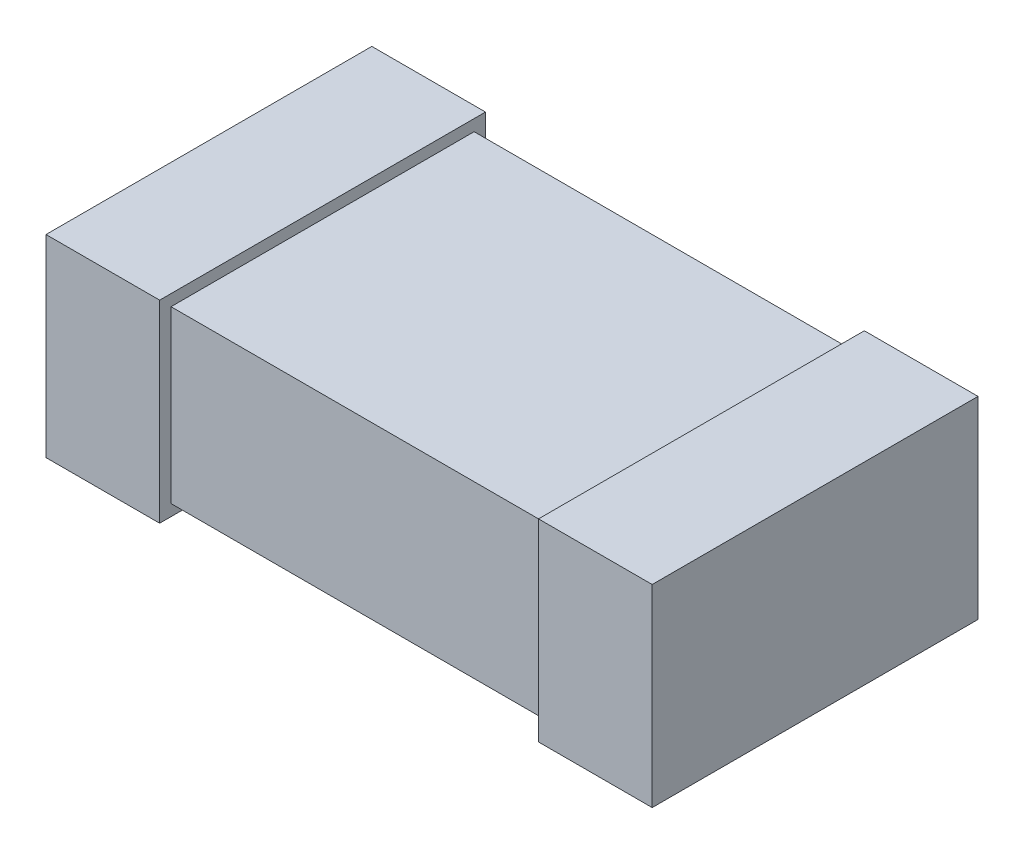
from build123d import *

# Parameters (mm, degrees)
SKETCH1_W           = 1
SKETCH1_H           = 0.8
BOSS_EXTRUDE1_DEPTH = 0.45
SKETCH2_W           = 0.3
SKETCH2_H           = 0.51
BOSS_EXTRUDE2_DEPTH = 0.86
SKETCH3_W           = 0.51
SKETCH3_H           = 0.86
BOSS_EXTRUDE3_DEPTH = 0.3


with BuildPart() as part:
    # Sketch1 → Boss-Extrude1 (new body)
    with BuildSketch(Plane(origin=(0, 0.45, 0), x_dir=(1, 0, 0), z_dir=(0, 1, 0))):
        Rectangle(SKETCH1_W, SKETCH1_H)
    extrude(amount=-BOSS_EXTRUDE1_DEPTH)

    # Sketch2 → Boss-Extrude2 (add)
    with BuildSketch(Plane(origin=(0, 0, -0.43), x_dir=(-1, 0, 0), z_dir=(0, 0, -1))):
        with Locations((0.65, 0.225)):
            Rectangle(SKETCH2_W, SKETCH2_H)
    extrude(amount=-BOSS_EXTRUDE2_DEPTH)

    # Sketch3 → Boss-Extrude3 (add)
    with BuildSketch(Plane(origin=(0.5, 0, 0), x_dir=(0, -1, 0), z_dir=(-1, 0, 0))):
        with Locations((-0.225, 0)):
            Rectangle(SKETCH3_W, SKETCH3_H)
    extrude(amount=-BOSS_EXTRUDE3_DEPTH)


solid = part.part
